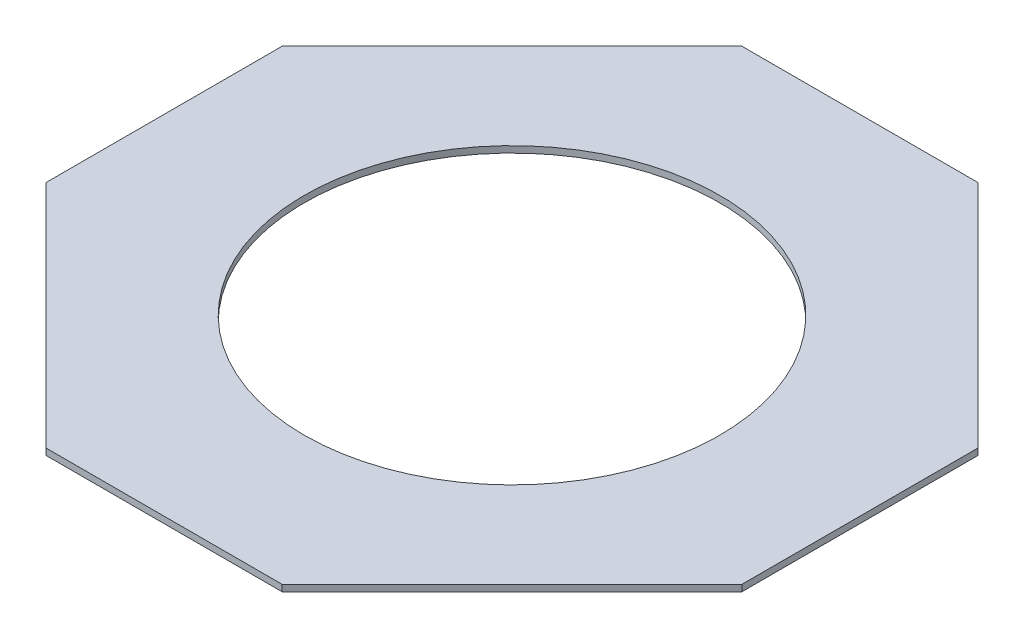
from build123d import *

# Parameters (mm, degrees)
SKETCH1_R           = 41.8
BOSS_EXTRUDE2_DEPTH = 1.3


with BuildPart() as part:
    # Sketch1 → Boss-Extrude2 (new body)
    with BuildSketch(Plane(origin=(0, 0, 0), x_dir=(1, 0, 0), z_dir=(0, 1, 0))):
        Polygon((23.75, 70), (-23.75, 70), (-70, 23.75), (-70, -23.75), (-23.75, -70), (23.75, -70), (70, -23.75), (70, 23.75), align=None)
        Circle(SKETCH1_R, mode=Mode.SUBTRACT)
    extrude(amount=BOSS_EXTRUDE2_DEPTH)


solid = part.part
